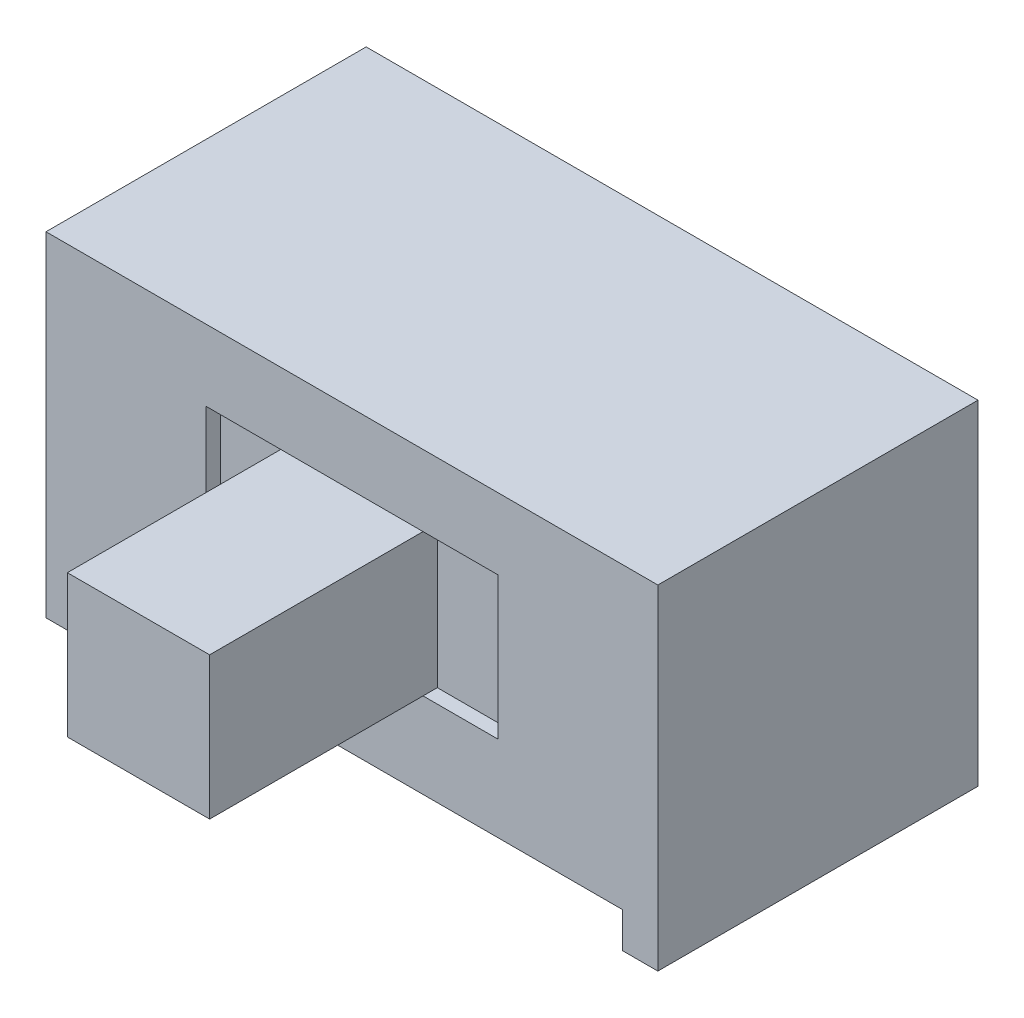
from build123d import *

# Parameters (mm, degrees)
SKETCH_1_W           = 8.6
SKETCH_1_H           = 4.5
EXTRUDE_1_DEPTH      = 4.7
SKETCH_2_W           = 4.1
SKETCH_2_H           = 2
CUT_EXTRUDE_1_DEPTH  = 0.2
CUT_EXTRUDE_2_REACH  = 6.5
SKETCH_4_W           = 7.6
SKETCH_4_H           = 0.5
SKETCH_5_W           = 2
SKETCH_5_H           = 2
EXTRUDE_2_DEPTH      = 3
EXTRUDE_2_DEPTH_BACK = 0.2


with BuildPart() as part:
    # 草图1 → 凸台-拉伸1 (new body)
    with BuildSketch(Plane(origin=(0, 0, 0), x_dir=(1, 0, 0), z_dir=(0, 1, 0))):
        with Locations((4.3, 2.25)):
            Rectangle(SKETCH_1_W, SKETCH_1_H)
    extrude(amount=EXTRUDE_1_DEPTH)

    # 草图2 → 切除-拉伸1 (cut)
    with BuildSketch(Plane.XY):
        with Locations((4.3, 2.7)):
            Rectangle(SKETCH_2_W, SKETCH_2_H)
    extrude(amount=-CUT_EXTRUDE_1_DEPTH, mode=Mode.SUBTRACT)

    # 草图4 → 切除-拉伸2 (cut, up to next)
    with BuildSketch(Plane.XY, mode=Mode.PRIVATE) as cut_extrude_2_sk1:
        with Locations((4.3, 0.25)):
            Rectangle(SKETCH_4_W, SKETCH_4_H)
    cut_extrude_2_tool1 = extrude(cut_extrude_2_sk1.sketch, amount=-CUT_EXTRUDE_2_REACH, mode=Mode.PRIVATE) & part.part
    add(cut_extrude_2_tool1.solids().sort_by_distance((4.3, 0.25, 0))[0], mode=Mode.SUBTRACT)

    # 草图5 → 凸台-拉伸2 (add, two sides)
    with BuildSketch(Plane.XY) as extrude_2_sk:
        with Locations((4.3, 2.7)):
            Rectangle(SKETCH_5_W, SKETCH_5_H)
    extrude(amount=EXTRUDE_2_DEPTH)
    extrude(extrude_2_sk.sketch, amount=-EXTRUDE_2_DEPTH_BACK)


solid = part.part
